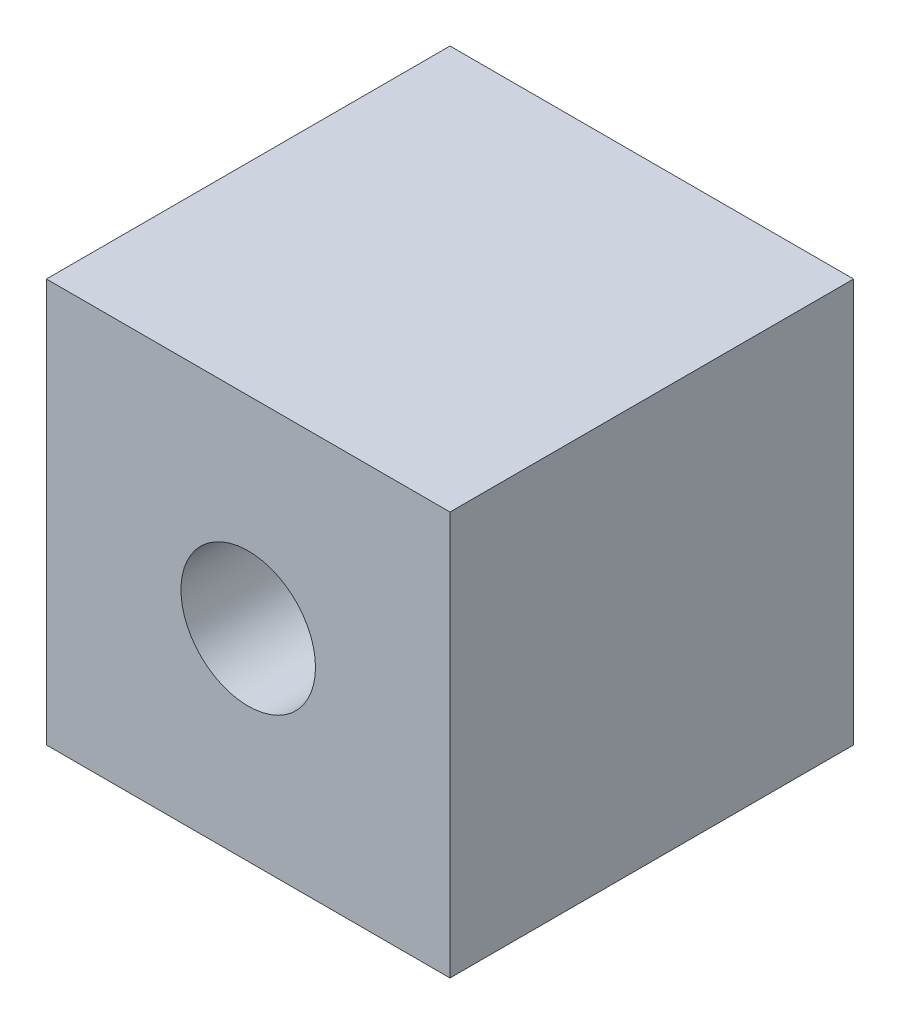
from build123d import *

# Parameters (mm, degrees)
SKETCH1_W           = 76.2
SKETCH1_H           = 76.2
BOSS_EXTRUDE1_DEPTH = 76.2
SKETCH2_R           = 12.7
CUT_EXTRUDE1_DEPTH  = 25.4


with BuildPart() as part:
    # Sketch1 → Boss-Extrude1 (new body)
    with BuildSketch(Plane.XY):
        Rectangle(SKETCH1_W, SKETCH1_H)
    extrude(amount=BOSS_EXTRUDE1_DEPTH)

    # Sketch2 → Cut-Extrude1 (cut)
    with BuildSketch(Plane.XY.offset(76.2)):
        Circle(SKETCH2_R)
    extrude(amount=-CUT_EXTRUDE1_DEPTH, mode=Mode.SUBTRACT)


solid = part.part
